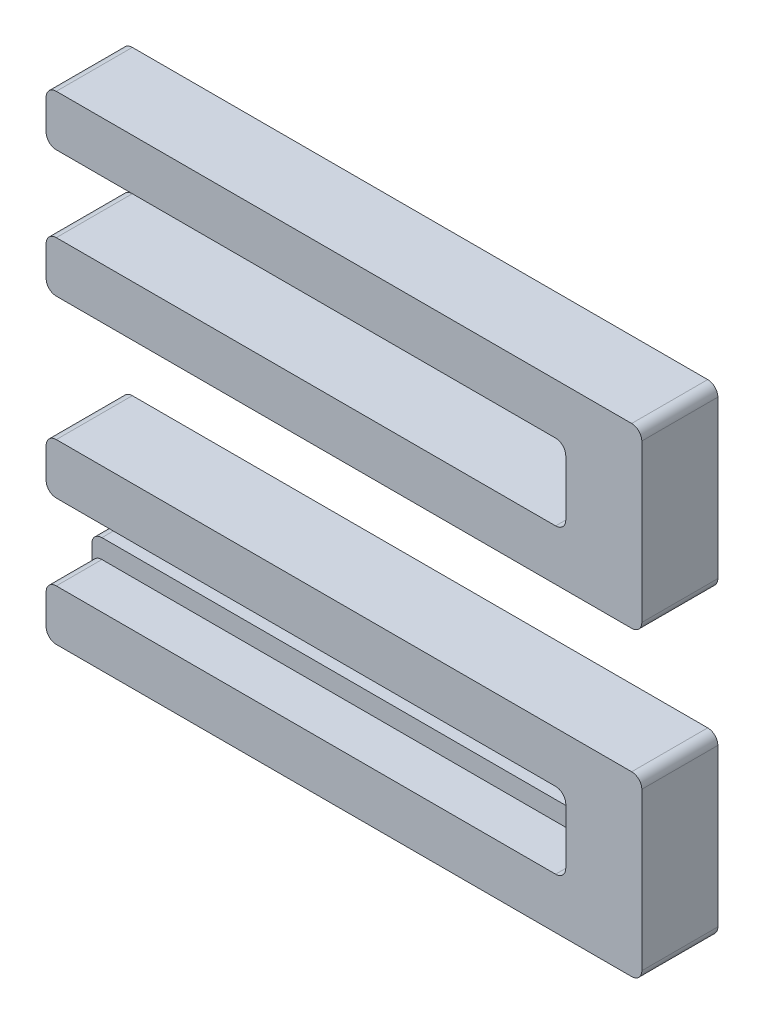
from build123d import *

# Parameters (mm, degrees)
BOSS_EXTRUDE1_DEPTH   = 3
BOSS_EXTRUDE1_2_DEPTH = 3
SKETCH2_4_W           = 20.5
SKETCH2_4_H           = 0.75
BOSS_EXTRUDE3_DEPTH   = 1.2
FILLET2_R             = 0.4
FILLET3_R             = 0.4


with BuildPart() as part:
    # Sketch2 → Boss-Extrude1 (new body)
    with BuildSketch(Plane.XY):
        Polygon((0, 2), (0, 0), (23.5, 0), (23.5, 7), (0, 7), (0, 5), (20.5, 5), (20.5, 2), align=None)
    extrude(amount=BOSS_EXTRUDE1_DEPTH)



with BuildPart() as body_2:
    # Sketch2 → Boss-Extrude1 2 (new body)
    with BuildSketch(Plane.XY):
        Polygon((20.5, -6.899471306), (20.5, -9.899471306), (0, -9.899471306), (0, -11.899471306), (23.5, -11.899471306), (23.5, -4.899471306), (0, -4.899471306), (0, -6.899471306), align=None)
    extrude(amount=BOSS_EXTRUDE1_2_DEPTH)


with BuildPart() as part_1:
    add(part.part)

    add(body_2.part)  # Boss-Extrude3 merges body 2
    # Sketch2_4 → Boss-Extrude3 (add)
    with BuildSketch(Plane.XY):
        with Locations((10.25, 4.625)):
            Rectangle(SKETCH2_4_W, SKETCH2_4_H)
        with Locations((10.25, -9.524471306)):
            Rectangle(SKETCH2_4_W, SKETCH2_4_H)
    extrude(amount=BOSS_EXTRUDE3_DEPTH)

    # Fillet2
    fillet2_edges = [part_1.edges().sort_by_distance(p)[0] for p in [
        (0, 5, 2.1),
        (20.5, 2, 1.5),
        (20.5, 4.25, 0.6),
        (20.5, 5, 2.1),
        (23.5, 7, 1.5),
        (23.5, 0, 1.5),
        (0, 0, 1.5),
        (0, 2, 1.5),
        (0, 4.25, 0.6),
        (0, 7, 1.5),
    ]]
    fillet(fillet2_edges, radius=FILLET2_R)

    # Fillet3
    fillet3_edges = [part_1.edges().sort_by_distance(p)[0] for p in [
        (23.5, -11.899471306, 1.5),
        (23.5, -4.899471306, 1.5),
        (20.5, -6.899471306, 1.5),
        (20.5, -9.899471306, 2.1),
        (20.5, -9.149471306, 0.6),
        (0, -11.899471306, 1.5),
        (0, -9.899471306, 2.1),
        (0, -9.149471306, 0.6),
        (0, -4.899471306, 1.5),
        (0, -6.899471306, 1.5),
    ]]
    fillet(fillet3_edges, radius=FILLET3_R)


solid = part_1.part
